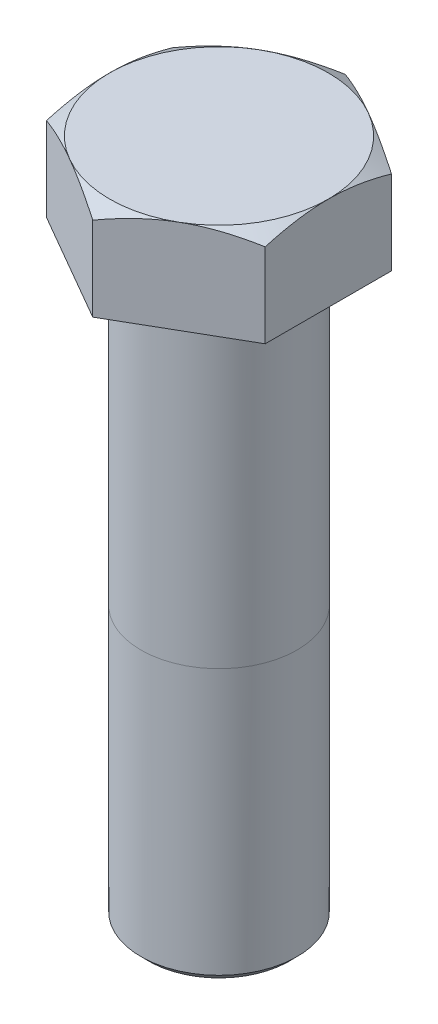
from build123d import *

# Parameters (mm, degrees)
BOSS_EXTRUDE1_DEPTH = 12
SKETCH2_OUTSIDE_W   = 80.454
SKETCH2_OUTSIDE_H   = 84.786
SKETCH2_OUTSIDE_R   = 14
CUT_EXTRUDE1_DEPTH  = 12
CUT_EXTRUDE1_TAPER  = 60
SKETCH3_R           = 10
BOSS_EXTRUDE2_DEPTH = 75
CHAMFER1_SIZE       = 1


with BuildPart() as part:
    # Sketch1 → Boss-Extrude1 (new body)
    with BuildSketch(Plane(origin=(0, 0, 0), x_dir=(1, 0, 0), z_dir=(0, 1, 0))):
        Polygon((0, 16.165807537), (-14, 8.082903769), (-14, -8.082903769), (0, -16.165807537), (14, -8.082903769), (14, 8.082903769), align=None)
    extrude(amount=BOSS_EXTRUDE1_DEPTH)

    # Sketch2 outside → Cut-Extrude1 (cut)
    with BuildSketch(Plane(origin=(0, 12, 0), x_dir=(1, 0, 0), z_dir=(0, 1, 0))):
        Rectangle(SKETCH2_OUTSIDE_W, SKETCH2_OUTSIDE_H)
        Circle(SKETCH2_OUTSIDE_R, mode=Mode.SUBTRACT)
    extrude(amount=-CUT_EXTRUDE1_DEPTH, taper=CUT_EXTRUDE1_TAPER, mode=Mode.SUBTRACT)

    # Sketch3 → Boss-Extrude2 (add)
    with BuildSketch(Plane.XZ):
        Circle(SKETCH3_R)
    extrude(amount=BOSS_EXTRUDE2_DEPTH)

    # Chamfer1
    chamfer1_edges = [part.edges().sort_by_distance(p)[0] for p in [
        (-10, -75, 0),
    ]]
    chamfer(chamfer1_edges, length=CHAMFER1_SIZE)


solid = part.part
